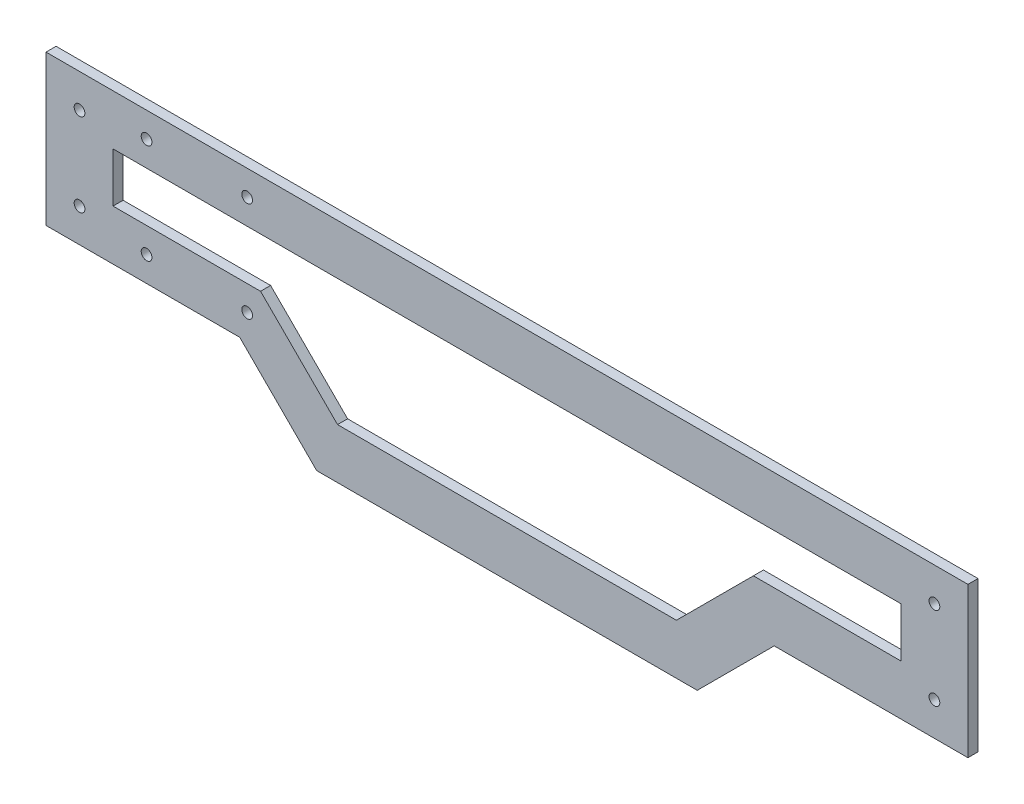
from build123d import *

# Parameters (mm, degrees)
SKETCH1_R          = 1.6
EXTRUDE1_DEPTH     = 3
SKETCH2_R          = 1.6
CUT_EXTRUDE1_DEPTH = 5


with BuildPart() as part:
    # Sketch1 → Extrude1 (new body)
    with BuildSketch(Plane.XY):
        Polygon((-21.510078765, 432.284503285), (253.489921235, 432.284503285), (253.489921235, 387.497048214), (195.708175305, 387.497048214), (172.745594885, 364.534467794), (59.234247585, 364.534467794), (36.271667166, 387.497048214), (-21.510078765, 387.497048214), align=None)
        with Locations((-11.510078765, 422.284503285)):
            Circle(SKETCH1_R, mode=Mode.SUBTRACT)
        with Locations((-11.510078765, 397.497048214)):
            Circle(SKETCH1_R, mode=Mode.SUBTRACT)
        with Locations((243.489921235, 397.497048214)):
            Circle(SKETCH1_R, mode=Mode.SUBTRACT)
        with Locations((243.489921235, 422.284503285)):
            Circle(SKETCH1_R, mode=Mode.SUBTRACT)
        Polygon((-1.510078765, 417.284503285), (233.489921235, 417.284503285), (233.489921235, 402.497048214), (189.494971869, 402.497048214), (166.53239145, 379.534467794), (65.44745102, 379.534467794), (42.484870601, 402.497048214), (-1.510078765, 402.497048214), align=None, mode=Mode.SUBTRACT)
    extrude(amount=EXTRUDE1_DEPTH)

    # Sketch2 → Cut-Extrude1 (cut)
    with BuildSketch(Plane(origin=(0, 0, 0), x_dir=(-1, 0, 0), z_dir=(0, 0, -1))):
        with Locations((-38.489921235, 424.784503285)):
            Circle(SKETCH2_R)
        with Locations((-8.489921235, 424.784503285)):
            Circle(SKETCH2_R)
        with Locations((-38.489921235, 394.997048214)):
            Circle(SKETCH2_R)
        with Locations((-8.489921235, 394.997048214)):
            Circle(SKETCH2_R)
    extrude(amount=-CUT_EXTRUDE1_DEPTH, mode=Mode.SUBTRACT)


solid = part.part
